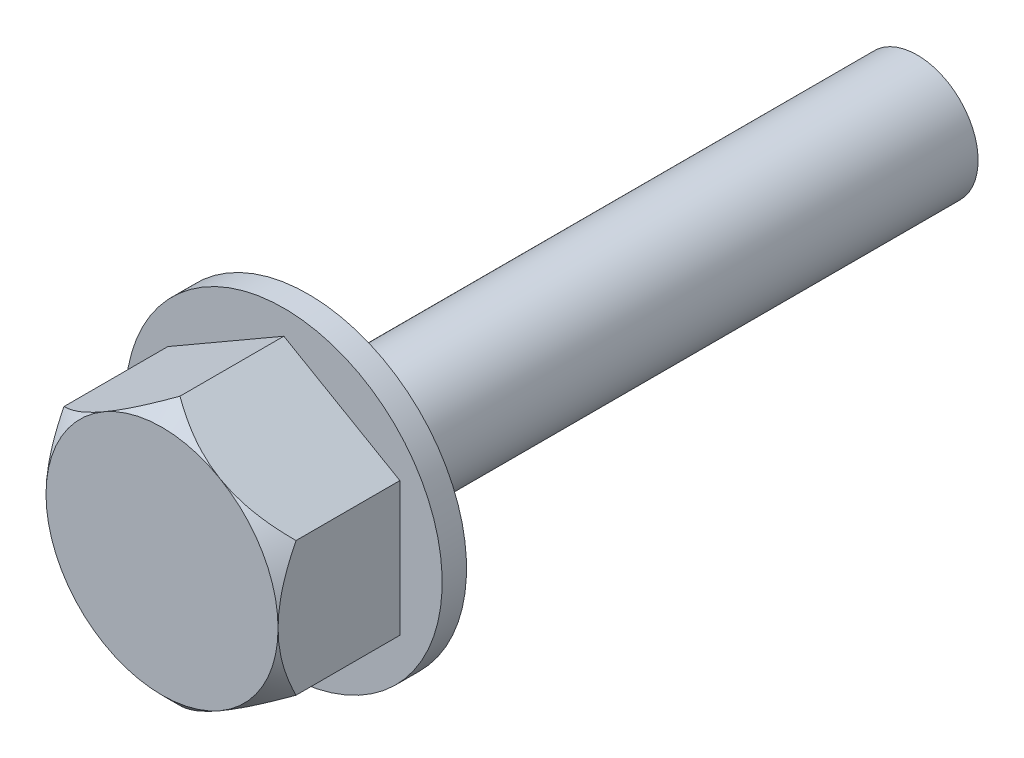
from build123d import *

# Parameters (mm, degrees)
BOSS_EXTRUDE1_DEPTH = 5
SKETCH2_OUTSIDE_W   = 24.604
SKETCH2_OUTSIDE_H   = 26.078
SKETCH2_OUTSIDE_R   = 4.763139721
CUT_EXTRUDE2_DEPTH  = 5
CUT_EXTRUDE2_TAPER  = 45
SKETCH5_R           = 6.5
BOSS_EXTRUDE2_DEPTH = 1
SKETCH6_R           = 2.5
BOSS_EXTRUDE3_DEPTH = 25


with BuildPart() as part:
    # Sketch1 → Boss-Extrude1 (new body)
    with BuildSketch(Plane.XY):
        Polygon((0, -5.5), (4.763139721, -2.75), (4.763139721, 2.75), (0, 5.5), (-4.763139721, 2.75), (-4.763139721, -2.75), align=None)
    extrude(amount=-BOSS_EXTRUDE1_DEPTH)

    # Sketch2 outside → Cut-Extrude2 (cut)
    with BuildSketch(Plane.XY):
        Rectangle(SKETCH2_OUTSIDE_W, SKETCH2_OUTSIDE_H)
        Circle(SKETCH2_OUTSIDE_R, mode=Mode.SUBTRACT)
    extrude(amount=-CUT_EXTRUDE2_DEPTH, taper=CUT_EXTRUDE2_TAPER, mode=Mode.SUBTRACT)

    # Sketch5 → Boss-Extrude2 (add)
    with BuildSketch(Plane(origin=(0, 0, -5), x_dir=(-1, 0, 0), z_dir=(0, 0, -1))):
        Circle(SKETCH5_R)
    extrude(amount=BOSS_EXTRUDE2_DEPTH)

    # Sketch6 → Boss-Extrude3 (add)
    with BuildSketch(Plane(origin=(0, 0, -6), x_dir=(-1, 0, 0), z_dir=(0, 0, -1))):
        Circle(SKETCH6_R)
    extrude(amount=BOSS_EXTRUDE3_DEPTH)


solid = part.part
